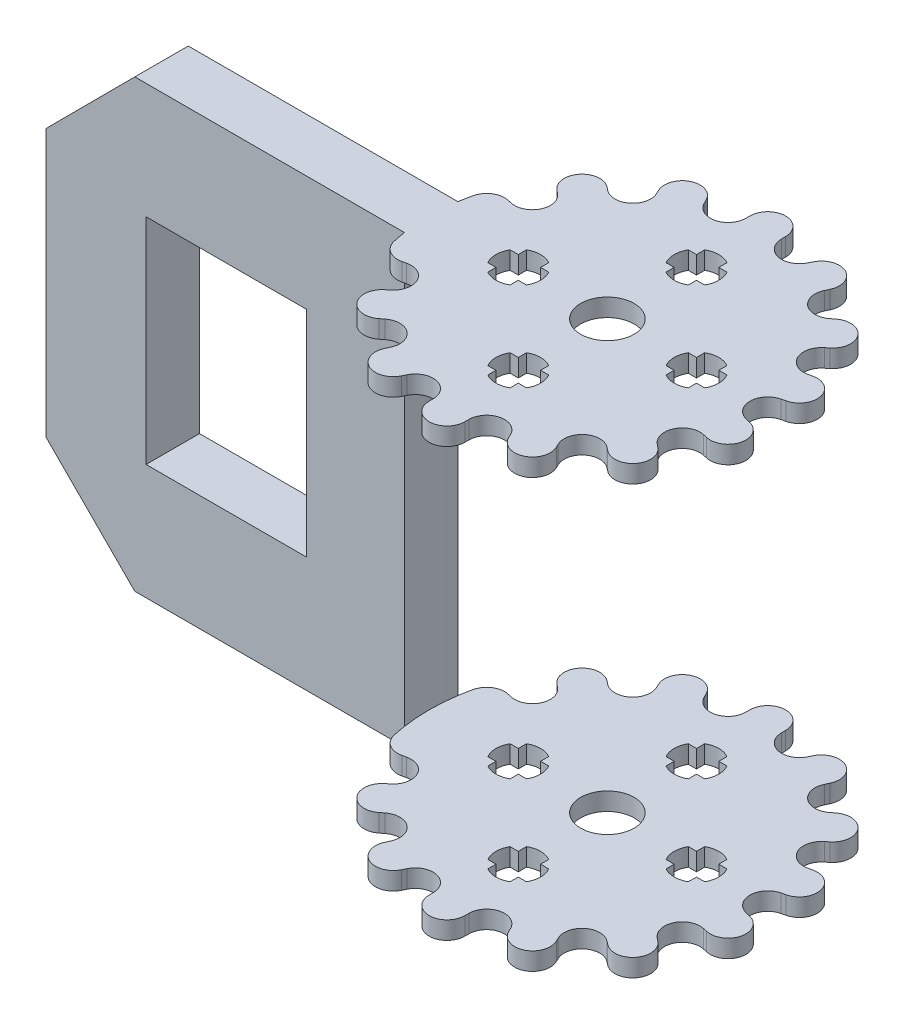
from build123d import *

# Parameters (mm, degrees)
SALIENTE_EXTRUIR1_DEPTH = 50
SALIENTE_EXTRUIR2_DEPTH = 2
CORTAR_EXTRUIR2_DEPTH   = 2
CROQUIS3_R              = 3
CORTAR_EXTRUIR3_DEPTH   = 2
CORTAR_EXTRUIR6_DEPTH   = 51
CORTAR_EXTRUIR7_DEPTH   = 51
CROQUIS10_W             = 18.022825887
CROQUIS10_H             = 24.077095022
CORTAR_EXTRUIR8_DEPTH   = 10
CORTAR_EXTRUIR9_DEPTH   = 51


with BuildPart() as part:
    # Croquis1 → Saliente-Extruir1 (new body)
    with BuildSketch(Plane(origin=(0, 0, 0), x_dir=(1, 0, 0), z_dir=(0, 1, 0))):
        with BuildLine():
            Line((-60, -14), (-60, -20))
            Line((-60, -20), (0, -20))
            ThreePointArc((0, -20), (-7.633172964, -18.486066929), (-14.110734629, -14.17346705))
            ThreePointArc((-14.110734629, -14.17346705), (-14.197060684, -14.086996412), (-14.282856857, -14))
            ThreePointArc((-14.282856857, -14), (-19.031883923, -6.147145218), (-19.773719933, 3))
            Line((-19.773719933, 3), (-60, 3))
            Line((-60, 3), (-60, -14))
        make_face()
    extrude(amount=SALIENTE_EXTRUIR1_DEPTH)

    # Croquis1_3 → Saliente-Extruir2 (add)
    with BuildSketch(Plane(origin=(0, 0, 0), x_dir=(1, 0, 0), z_dir=(0, 1, 0))):
        with BuildLine():
            ThreePointArc((-14.110734629, -14.17346705), (-7.633172964, -18.486066929), (0, -20))
            ThreePointArc((0, -20), (15.165750888, 13.03840481), (-19.773719933, 3))
            ThreePointArc((-19.773719933, 3), (-19.031883923, -6.147145218), (-14.282856857, -14))
            ThreePointArc((-14.282856857, -14), (-14.197060684, -14.086996412), (-14.110734629, -14.17346705))
        make_face()
    saliente_extruir2 = extrude(amount=SALIENTE_EXTRUIR2_DEPTH)

    # Simetría1: Saliente-Extruir2 across plane
    add(saliente_extruir2.mirror(Plane.ZX.offset(25)))

    # Croquis2 → Cortar-Extruir2 (cut)
    with BuildSketch(Plane(origin=(0, 50, 0), x_dir=(1, 0, 0), z_dir=(0, 1, 0))):
        with BuildLine():
            ThreePointArc((0, 20), (1.414213562, 19.414213562), (2, 18))
            Line((2, 18), (2.005376811, 17.548702419))
            ThreePointArc((2.005376811, 17.548702419), (3.560334943, 15.598846595), (5.807314547, 16.680934941))
            Line((5.807314547, 16.680934941), (6.007969568, 17.0852071))
            ThreePointArc((6.007969568, 17.0852071), (7.149347796, 18.105205799), (8.67767214, 18.01937863))
            ThreePointArc((8.67767214, 18.01937863), (4.45041725, 19.49855857), (0, 20))
        make_face()
        with BuildLine():
            ThreePointArc((-2, 18), (-1.414213562, 19.414213562), (0, 20))
            ThreePointArc((0, 20), (-4.450418694, 19.49855824), (-8.67767481, 18.019377345))
            ThreePointArc((-8.67767481, 18.019377345), (-7.149349195, 18.105206288), (-6.007969568, 17.0852071))
            Line((-6.007969568, 17.0852071), (-5.807314547, 16.680934941))
            ThreePointArc((-5.807314547, 16.680934941), (-3.560334943, 15.598846595), (-2.005376811, 17.548702419))
            Line((-2.005376811, 17.548702419), (-2, 18))
        make_face()
        with BuildLine():
            ThreePointArc((15.636631756, 12.469793396), (12.469796212, 15.63662951), (8.67767214, 18.01937863))
            ThreePointArc((8.67767214, 18.01937863), (9.69767348, 16.87799913), (9.61184504, 15.349672144))
            Line((9.61184504, 15.349672144), (9.420878698, 14.940734163))
            ThreePointArc((9.420878698, 14.940734163), (9.97583683, 12.509303719), (12.469796037, 12.509303719))
            Line((12.469796037, 12.509303719), (12.825987081, 12.786479398))
            ThreePointArc((12.825987081, 12.786479398), (14.296897315, 13.210240664), (15.636631756, 12.469793396))
        make_face()
        with BuildLine():
            ThreePointArc((-9.61184504, 15.349672144), (-9.69767397, 16.877997732), (-8.67767481, 18.019377345))
            ThreePointArc((-8.67767481, 18.019377345), (-12.469796035, 15.636629651), (-15.636629626, 12.469796066))
            ThreePointArc((-15.636629626, 12.469796066), (-14.296895618, 13.210240855), (-12.825987081, 12.786479398))
            Line((-12.825987081, 12.786479398), (-12.469796037, 12.509303719))
            ThreePointArc((-12.469796037, 12.509303719), (-9.97583683, 12.509303719), (-9.420878698, 14.940734163))
            Line((-9.420878698, 14.940734163), (-9.61184504, 15.349672144))
        make_face()
        with BuildLine():
            ThreePointArc((19.498557572, 4.450421621), (18.019377436, 8.67767462), (15.636631756, 12.469793396))
            ThreePointArc((15.636631756, 12.469793396), (16.060390915, 10.998885803), (15.319946288, 9.659153469))
            Line((15.319946288, 9.659153469), (14.970460019, 9.373570269))
            ThreePointArc((14.970460019, 9.373570269), (14.415501886, 6.942139826), (16.66248149, 5.86005148))
            Line((16.66248149, 5.86005148), (17.103660551, 5.955232636))
            ThreePointArc((17.103660551, 5.955232636), (18.612765295, 5.698826012), (19.498557572, 4.450421621))
        make_face()
        with BuildLine():
            ThreePointArc((-15.319946288, 9.659153469), (-16.060391106, 10.9988875), (-15.636629626, 12.469796066))
            ThreePointArc((-15.636629626, 12.469796066), (-18.019377339, 8.677674822), (-19.498558233, 4.450418728))
            ThreePointArc((-19.498558233, 4.450418728), (-18.612766551, 5.698825223), (-17.103660551, 5.955232636))
            Line((-17.103660551, 5.955232636), (-16.66248149, 5.86005148))
            ThreePointArc((-16.66248149, 5.86005148), (-14.415501886, 6.942139826), (-14.970460019, 9.373570269))
            Line((-14.970460019, 9.373570269), (-15.319946288, 9.659153469))
        make_face()
        with BuildLine():
            ThreePointArc((19.498557608, -4.450421462), (20, 8.1e-08), (19.498557572, 4.450421621))
            ThreePointArc((19.498557572, 4.450421621), (19.24215162, 2.941313936), (17.993744287, 2.055520987))
            Line((17.993744287, 2.055520987), (17.554958132, 1.949855824))
            ThreePointArc((17.554958132, 1.949855824), (16, 0), (17.554958132, -1.949855824))
            Line((17.554958132, -1.949855824), (17.993744287, -2.055520987))
            ThreePointArc((17.993744287, -2.055520987), (19.242151577, -2.941313867), (19.498557608, -4.450421462))
        make_face()
        with BuildLine():
            ThreePointArc((15.636630586, -12.469794863), (18.019377065, -8.677675392), (19.498557608, -4.450421462))
            ThreePointArc((19.498557608, -4.450421462), (18.612765364, -5.698825969), (17.103660551, -5.955232636))
            Line((17.103660551, -5.955232636), (16.66248149, -5.86005148))
            ThreePointArc((16.66248149, -5.86005148), (14.415501886, -6.942139826), (14.970460019, -9.373570269))
            Line((14.970460019, -9.373570269), (15.319946288, -9.659153469))
            ThreePointArc((15.319946288, -9.659153469), (16.06039102, -10.998886735), (15.636630586, -12.469794863))
        make_face()
        with BuildLine():
            ThreePointArc((8.677674776, -18.019377361), (12.469796622, -15.636629183), (15.636630586, -12.469794863))
            ThreePointArc((15.636630586, -12.469794863), (14.296896383, -13.210240769), (12.825987081, -12.786479398))
            Line((12.825987081, -12.786479398), (12.469796037, -12.509303719))
            ThreePointArc((12.469796037, -12.509303719), (9.97583683, -12.509303719), (9.420878698, -14.940734163))
            Line((9.420878698, -14.940734163), (9.61184504, -15.349672144))
            ThreePointArc((9.61184504, -15.349672144), (9.697673964, -16.877997749), (8.677674776, -18.019377361))
        make_face()
        with BuildLine():
            ThreePointArc((0, -20), (4.450418676, -19.498558244), (8.677674776, -18.019377361))
            ThreePointArc((8.677674776, -18.019377361), (7.149349177, -18.105206282), (6.007969568, -17.0852071))
            Line((6.007969568, -17.0852071), (5.807314547, -16.680934941))
            ThreePointArc((5.807314547, -16.680934941), (3.560334943, -15.598846595), (2.005376811, -17.548702419))
            Line((2.005376811, -17.548702419), (2, -18))
            ThreePointArc((2, -18), (1.414213562, -19.414213562), (0, -20))
        make_face()
    cortar_extruir2 = extrude(amount=-CORTAR_EXTRUIR2_DEPTH, mode=Mode.SUBTRACT)

    # Simetría2: Cortar-Extruir2 across plane
    add(cortar_extruir2.mirror(Plane.ZX.offset(25)), mode=Mode.SUBTRACT)

    # Croquis3 → Cortar-Extruir3 (cut)
    with BuildSketch(Plane(origin=(0, 50, 0), x_dir=(1, 0, 0), z_dir=(0, 1, 0))):
        Circle(CROQUIS3_R)
    cortar_extruir3 = extrude(amount=-CORTAR_EXTRUIR3_DEPTH, mode=Mode.SUBTRACT)

    # Simetría3: Cortar-Extruir3 across plane
    add(cortar_extruir3.mirror(Plane.ZX.offset(25)), mode=Mode.SUBTRACT)

    # Croquis8 → Cortar-Extruir6 (cut, through all)
    with BuildSketch(Plane(origin=(0, 50, 0), x_dir=(1, 0, 0), z_dir=(0, 1, 0))):
        with BuildLine():
            Line((-60, -3), (-19.773719933, -3))
            ThreePointArc((-19.773719933, -3), (-13.03840481, -15.165750888), (0, -20))
            Line((0, -20), (-60, -20))
            Line((-60, -20), (-60, -3))
        make_face()
    extrude(amount=-CORTAR_EXTRUIR6_DEPTH, mode=Mode.SUBTRACT)

    # Croquis9 → Cortar-Extruir7 (cut, through all)
    with BuildSketch(Plane(origin=(0, 50, 0), x_dir=(1, 0, 0), z_dir=(0, 1, 0))):
        with BuildLine():
            ThreePointArc((-19.498558244, -4.450418679), (-18.019377356, -8.677674786), (-15.636629645, -12.469796043))
            ThreePointArc((-15.636629645, -12.469796043), (-16.060391105, -10.998887485), (-15.319946288, -9.659153469))
            Line((-15.319946288, -9.659153469), (-14.970460019, -9.373570269))
            ThreePointArc((-14.970460019, -9.373570269), (-14.415501886, -6.942139826), (-16.66248149, -5.86005148))
            Line((-16.66248149, -5.86005148), (-17.103660551, -5.955232636))
            ThreePointArc((-17.103660551, -5.955232636), (-18.612766572, -5.69882521), (-19.498558244, -4.450418679))
        make_face()
        with BuildLine():
            ThreePointArc((-15.636629645, -12.469796043), (-12.46979604, -15.636629647), (-8.677674795, -18.019377352))
            ThreePointArc((-8.677674795, -18.019377352), (-9.697673967, -16.877997739), (-9.61184504, -15.349672144))
            Line((-9.61184504, -15.349672144), (-9.420878698, -14.940734163))
            ThreePointArc((-9.420878698, -14.940734163), (-9.97583683, -12.509303719), (-12.469796037, -12.509303719))
            Line((-12.469796037, -12.509303719), (-12.825987081, -12.786479398))
            ThreePointArc((-12.825987081, -12.786479398), (-14.296895633, -13.210240854), (-15.636629645, -12.469796043))
        make_face()
        with BuildLine():
            Line((-2, -18), (-2.005376811, -17.548702419))
            ThreePointArc((-2.005376811, -17.548702419), (-3.560334943, -15.598846595), (-5.807314547, -16.680934941))
            Line((-5.807314547, -16.680934941), (-6.007969568, -17.0852071))
            ThreePointArc((-6.007969568, -17.0852071), (-7.149349187, -18.105206285), (-8.677674795, -18.019377352))
            ThreePointArc((-8.677674795, -18.019377352), (-4.450418686, -19.498558242), (0, -20))
            ThreePointArc((0, -20), (-1.414213562, -19.414213562), (-2, -18))
        make_face()
    extrude(amount=-CORTAR_EXTRUIR7_DEPTH, mode=Mode.SUBTRACT)

    # Croquis10 → Cortar-Extruir8 (cut)
    with BuildSketch(Plane.XY.offset(3)):
        Polygon((-50.032462087, 50), (-60, 50), (-60, 40), align=None)
        with Locations((-39.759791179, 25)):
            Rectangle(CROQUIS10_W, CROQUIS10_H)
        Polygon((-50.032462087, 0), (-60, 10), (-60, 0), align=None)
    extrude(amount=-CORTAR_EXTRUIR8_DEPTH, mode=Mode.SUBTRACT)

    # Croquis15 → Cortar-Extruir9 (cut, through all)
    with BuildSketch(Plane(origin=(0, 50, 0), x_dir=(1, 0, 0), z_dir=(0, 1, 0))):
        with BuildLine():
            ThreePointArc((-1.25, 12.165063509), (-0.647047613, 12.414814566), (0, 12.5))
            ThreePointArc((0, 12.5), (0.647047613, 12.414814566), (1.25, 12.165063509))
            Line((1.25, 12.165063509), (1.25, 11.25))
            Line((1.25, 11.25), (2.165063509, 11.25))
            ThreePointArc((2.165063509, 11.25), (2.414814566, 10.647047613), (2.5, 10))
            ThreePointArc((2.5, 10), (2.414814566, 9.352952387), (2.165063509, 8.75))
            Line((2.165063509, 8.75), (1.25, 8.75))
            Line((1.25, 8.75), (1.25, 7.834936491))
            ThreePointArc((1.25, 7.834936491), (0.647047613, 7.585185434), (0, 7.5))
            ThreePointArc((0, 7.5), (-0.647047613, 7.585185434), (-1.25, 7.834936491))
            Line((-1.25, 7.834936491), (-1.25, 8.75))
            Line((-1.25, 8.75), (-2.165063509, 8.75))
            ThreePointArc((-2.165063509, 8.75), (-2.414814566, 9.352952387), (-2.5, 10))
            ThreePointArc((-2.5, 10), (-2.414814566, 10.647047613), (-2.165063509, 11.25))
            Line((-2.165063509, 11.25), (-1.25, 11.25))
            Line((-1.25, 11.25), (-1.25, 12.165063509))
        make_face()
        with BuildLine():
            ThreePointArc((-10, -2.5), (-10.647047613, -2.414814566), (-11.25, -2.165063509))
            Line((-11.25, -2.165063509), (-11.25, -1.25))
            Line((-11.25, -1.25), (-12.165063509, -1.25))
            ThreePointArc((-12.165063509, -1.25), (-12.414814566, -0.647047613), (-12.5, 0))
            ThreePointArc((-12.5, 0), (-12.414814566, 0.647047613), (-12.165063509, 1.25))
            Line((-12.165063509, 1.25), (-11.25, 1.25))
            Line((-11.25, 1.25), (-11.25, 2.165063509))
            ThreePointArc((-11.25, 2.165063509), (-10.647047613, 2.414814566), (-10, 2.5))
            ThreePointArc((-10, 2.5), (-9.352952387, 2.414814566), (-8.75, 2.165063509))
            Line((-8.75, 2.165063509), (-8.75, 1.25))
            Line((-8.75, 1.25), (-7.834936491, 1.25))
            ThreePointArc((-7.834936491, 1.25), (-7.585185434, 0.647047613), (-7.5, 0))
            ThreePointArc((-7.5, 0), (-7.585185434, -0.647047613), (-7.834936491, -1.25))
            Line((-7.834936491, -1.25), (-8.75, -1.25))
            Line((-8.75, -1.25), (-8.75, -2.165063509))
            ThreePointArc((-8.75, -2.165063509), (-9.352952387, -2.414814566), (-10, -2.5))
        make_face()
        with BuildLine():
            ThreePointArc((10, 2.5), (10.647047613, 2.414814566), (11.25, 2.165063509))
            Line((11.25, 2.165063509), (11.25, 1.25))
            Line((11.25, 1.25), (12.165063509, 1.25))
            ThreePointArc((12.165063509, 1.25), (12.414814566, 0.647047613), (12.5, 0))
            ThreePointArc((12.5, 0), (12.414814566, -0.647047613), (12.165063509, -1.25))
            Line((12.165063509, -1.25), (11.25, -1.25))
            Line((11.25, -1.25), (11.25, -2.165063509))
            ThreePointArc((11.25, -2.165063509), (10.647047613, -2.414814566), (10, -2.5))
            ThreePointArc((10, -2.5), (9.352952387, -2.414814566), (8.75, -2.165063509))
            Line((8.75, -2.165063509), (8.75, -1.25))
            Line((8.75, -1.25), (7.834936491, -1.25))
            ThreePointArc((7.834936491, -1.25), (7.585185434, -0.647047613), (7.5, 0))
            ThreePointArc((7.5, 0), (7.585185434, 0.647047613), (7.834936491, 1.25))
            Line((7.834936491, 1.25), (8.75, 1.25))
            Line((8.75, 1.25), (8.75, 2.165063509))
            ThreePointArc((8.75, 2.165063509), (9.352952387, 2.414814566), (10, 2.5))
        make_face()
        with BuildLine():
            ThreePointArc((2.5, -10), (2.414814566, -10.647047613), (2.165063509, -11.25))
            Line((2.165063509, -11.25), (1.25, -11.25))
            Line((1.25, -11.25), (1.25, -12.165063509))
            ThreePointArc((1.25, -12.165063509), (0.647047613, -12.414814566), (0, -12.5))
            ThreePointArc((0, -12.5), (-0.647047613, -12.414814566), (-1.25, -12.165063509))
            Line((-1.25, -12.165063509), (-1.25, -11.25))
            Line((-1.25, -11.25), (-2.165063509, -11.25))
            ThreePointArc((-2.165063509, -11.25), (-2.414814566, -10.647047613), (-2.5, -10))
            ThreePointArc((-2.5, -10), (-2.414814566, -9.352952387), (-2.165063509, -8.75))
            Line((-2.165063509, -8.75), (-1.25, -8.75))
            Line((-1.25, -8.75), (-1.25, -7.834936491))
            ThreePointArc((-1.25, -7.834936491), (-0.647047613, -7.585185434), (0, -7.5))
            ThreePointArc((0, -7.5), (0.647047613, -7.585185434), (1.25, -7.834936491))
            Line((1.25, -7.834936491), (1.25, -8.75))
            Line((1.25, -8.75), (2.165063509, -8.75))
            ThreePointArc((2.165063509, -8.75), (2.414814566, -9.352952387), (2.5, -10))
        make_face()
    extrude(amount=-CORTAR_EXTRUIR9_DEPTH, mode=Mode.SUBTRACT)


solid = part.part
